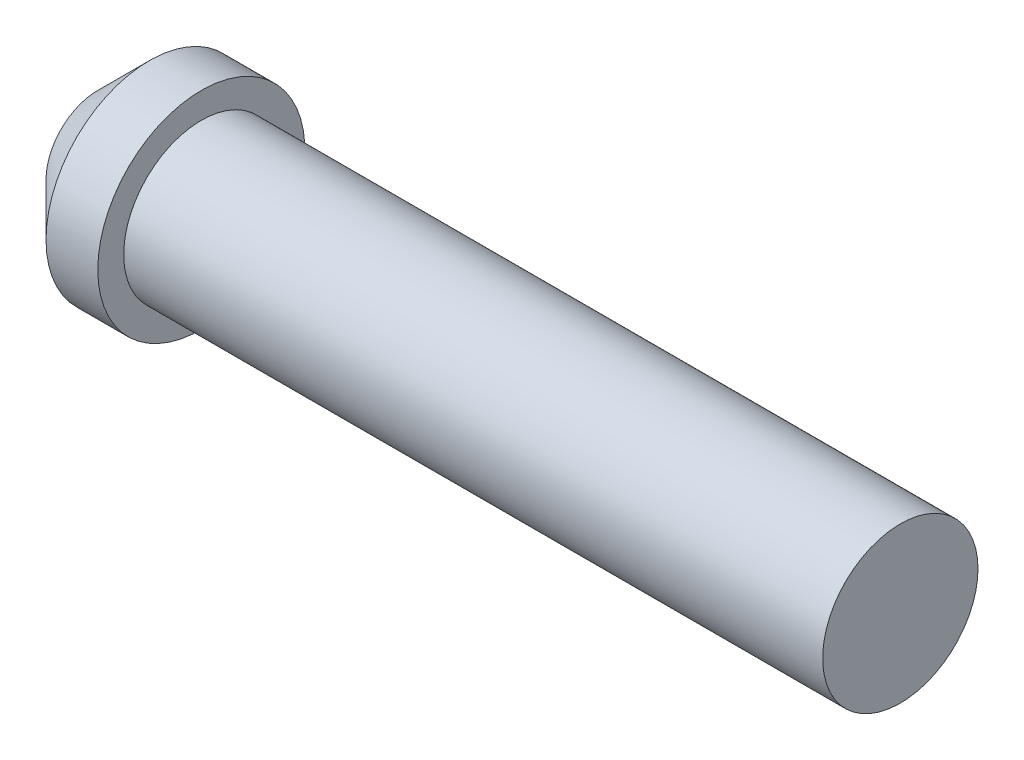
from build123d import *

# Parameters (mm, degrees)
SKETCH1_R           = 3
BOSS_EXTRUDE1_DEPTH = 27
SKETCH2_R           = 4
BOSS_EXTRUDE2_DEPTH = 4
CHAMFER1_SIZE       = 2


with BuildPart() as part:
    # Sketch1 → Boss-Extrude1 (new body)
    with BuildSketch(Plane(origin=(0, 0, 0), x_dir=(0, 0, -1), z_dir=(1, 0, 0))):
        Circle(SKETCH1_R)
    extrude(amount=BOSS_EXTRUDE1_DEPTH)

    # Sketch2 → Boss-Extrude2 (add)
    with BuildSketch(Plane.ZY):
        Circle(SKETCH2_R)
    extrude(amount=BOSS_EXTRUDE2_DEPTH)

    # Chamfer1
    chamfer1_edges = [part.edges().sort_by_distance(p)[0] for p in [
        (-4, 0, -4),
    ]]
    chamfer(chamfer1_edges, length=CHAMFER1_SIZE)


solid = part.part
